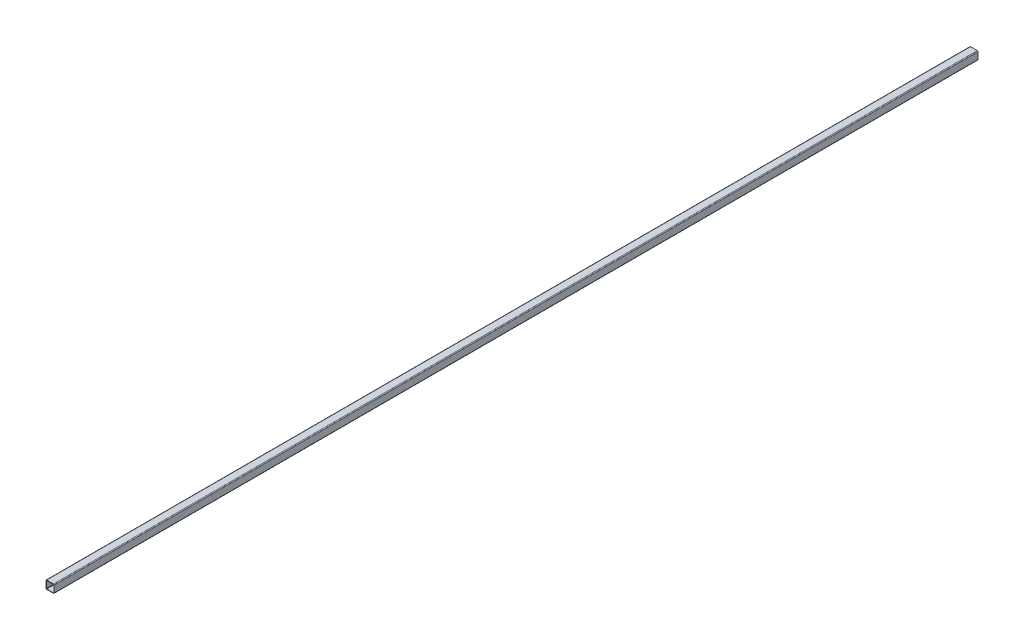
from build123d import *

# Parameters (mm, degrees)
BOSS_EXTRUDE1_DEPTH = 1563.6875


with BuildPart() as part:
    # Sketch1 → Boss-Extrude1 (new body, symmetric)
    with BuildSketch(Plane.XY):
        with BuildLine():
            Line((-11.2903, 13.8303), (11.2903, 13.8303))
            ThreePointArc((11.2903, 13.8303), (13.086351224, 13.086351224), (13.8303, 11.2903))
            Line((13.8303, 11.2903), (13.8303, -11.2903))
            ThreePointArc((13.8303, -11.2903), (13.086351224, -13.086351224), (11.2903, -13.8303))
            Line((11.2903, -13.8303), (-11.2903, -13.8303))
            ThreePointArc((-11.2903, -13.8303), (-13.086351224, -13.086351224), (-13.8303, -11.2903))
            Line((-13.8303, -11.2903), (-13.8303, 11.2903))
            ThreePointArc((-13.8303, 11.2903), (-13.086351224, 13.086351224), (-11.2903, 13.8303))
        make_face()
        with BuildLine():
            Line((-12.5603, 11.2903), (-12.5603, -11.2903))
            ThreePointArc((-12.5603, -11.2903), (-12.188325612, -12.188325612), (-11.2903, -12.5603))
            Line((-11.2903, -12.5603), (11.2903, -12.5603))
            ThreePointArc((11.2903, -12.5603), (12.188325612, -12.188325612), (12.5603, -11.2903))
            Line((12.5603, -11.2903), (12.5603, 11.2903))
            ThreePointArc((12.5603, 11.2903), (12.188325612, 12.188325612), (11.2903, 12.5603))
            Line((11.2903, 12.5603), (-11.2903, 12.5603))
            ThreePointArc((-11.2903, 12.5603), (-12.188325612, 12.188325612), (-12.5603, 11.2903))
        make_face(mode=Mode.SUBTRACT)
    extrude(amount=BOSS_EXTRUDE1_DEPTH, both=True)


solid = part.part
